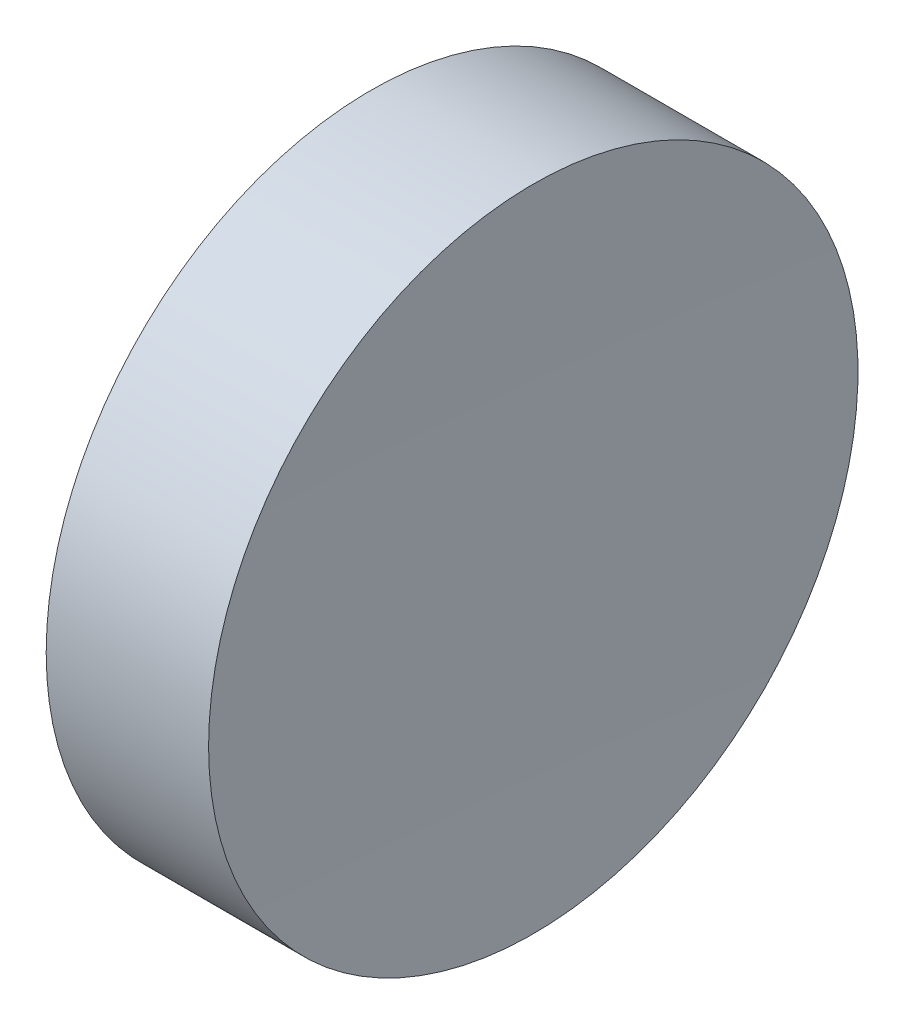
from build123d import *


with BuildPart() as part:
    # 草图1 → 旋转1 (revolve)
    with BuildSketch(Plane(origin=(0, 0, 0), x_dir=(1, 0, 0), z_dir=(0, 1, 0)), mode=Mode.PRIVATE) as revolve_1_sk:
        with BuildLine():
            Line((0, 0), (6.19, 0))
            ThreePointArc((6.19, 0), (6.230330632, 6.35051224), (6.351316023, 12.7))
            Line((6.351316023, 12.7), (0, 12.7))
            Line((0, 12.7), (0, 0))
        make_face()
    revolve(revolve_1_sk.sketch.rotate(Axis((0, 0, 0), (1, 0, 0)), 180), axis=Axis((0, 0, 0), (1, 0, 0)))  # turned: the seam where the file's is


solid = part.part
